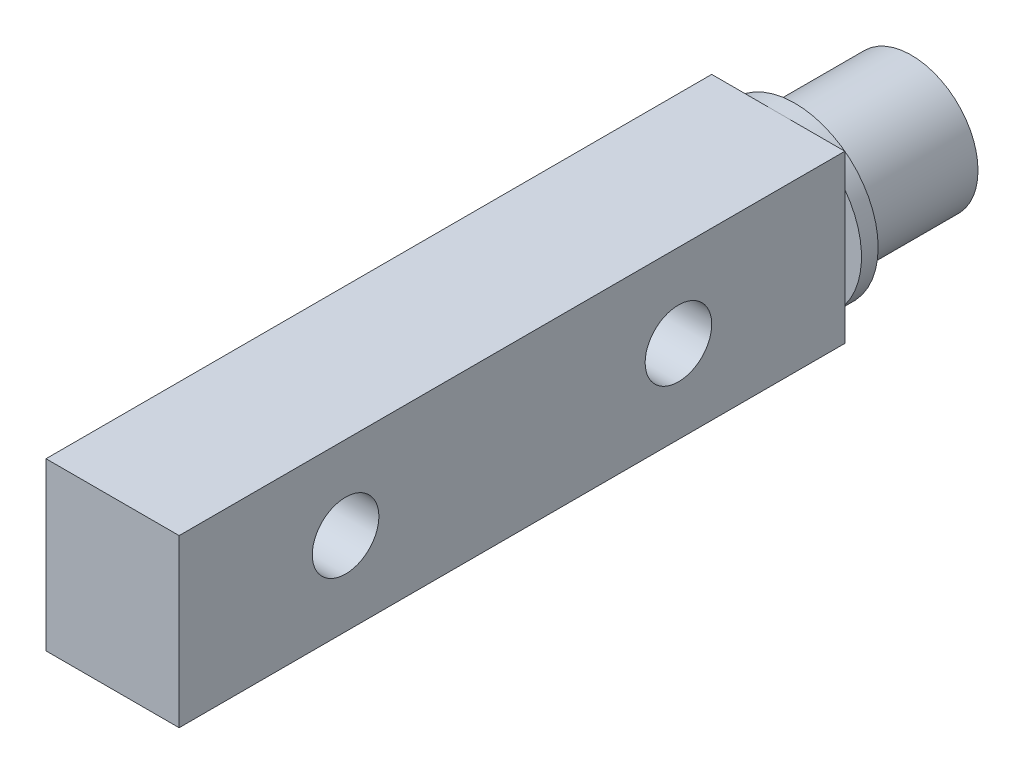
from build123d import *

# Parameters (mm, degrees)
SKETCH_1_R          = 4
EXTRUDE_1_DEPTH     = 7
SKETCH_2_R          = 5
EXTRUDE_2_DEPTH     = 1
SKETCH_3_W          = 8
SKETCH_3_H          = 10
EXTRUDE_3_DEPTH     = 40
CUT_EXTRUDE_1_REACH = 11
SKETCH_4_R          = 2


with BuildPart() as part:
    # Эскиз1 → Бобышка-Вытянуть1 (new body)
    with BuildSketch(Plane.XY):
        Circle(SKETCH_1_R)
    extrude(amount=EXTRUDE_1_DEPTH)

    # Эскиз2 → Бобышка-Вытянуть2 (add)
    with BuildSketch(Plane.XY.offset(7)):
        Circle(SKETCH_2_R)
    extrude(amount=EXTRUDE_2_DEPTH)

    # Эскиз3 → Бобышка-Вытянуть3 (add)
    with BuildSketch(Plane.XY.offset(8)):
        Rectangle(SKETCH_3_W, SKETCH_3_H)
    extrude(amount=EXTRUDE_3_DEPTH)

    # Эскиз4 → Вырез-Вытянуть1 (cut, up to next)
    with BuildSketch(Plane.ZY.offset(4), mode=Mode.PRIVATE) as cut_extrude_1_sk1:
        with Locations((18, 0)):
            Circle(SKETCH_4_R)
    cut_extrude_1_tool1 = extrude(cut_extrude_1_sk1.sketch, amount=-CUT_EXTRUDE_1_REACH, mode=Mode.PRIVATE) & part.part
    add(cut_extrude_1_tool1.solids().sort_by_distance((-4, 0, 18))[0], mode=Mode.SUBTRACT)
    # Эскиз4 → Вырез-Вытянуть1 (cut, up to next)
    with BuildSketch(Plane.ZY.offset(4), mode=Mode.PRIVATE) as cut_extrude_1_sk2:
        with Locations((38, 0)):
            Circle(SKETCH_4_R)
    cut_extrude_1_tool2 = extrude(cut_extrude_1_sk2.sketch, amount=-CUT_EXTRUDE_1_REACH, mode=Mode.PRIVATE) & part.part
    add(cut_extrude_1_tool2.solids().sort_by_distance((-4, 0, 38))[0], mode=Mode.SUBTRACT)


solid = part.part
